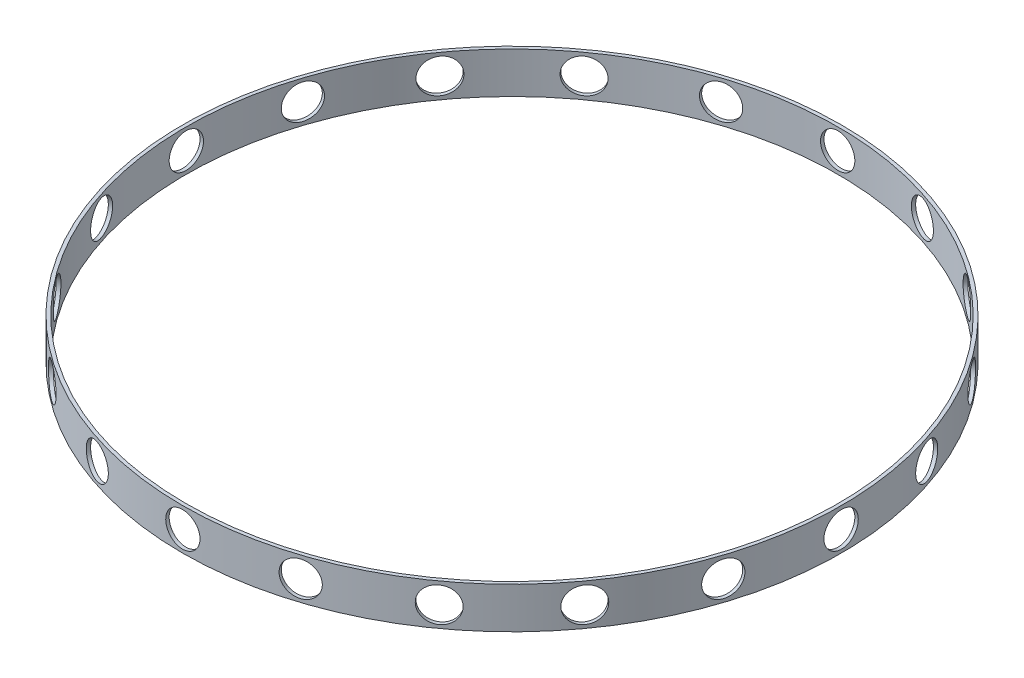
from build123d import *

# Parameters (mm, degrees)
SKETCH1_R           = 48
SKETCH1_R_2         = 47.5
BOSS_EXTRUDE2_DEPTH = 6
SKETCH5_R           = 2.5
CUT_EXTRUDE1_DEPTH  = 49
CIRPATTERN1_COUNT   = 20


with BuildPart() as part:
    # Sketch1 → Boss-Extrude2 (new body)
    with BuildSketch(Plane(origin=(0, 0, 0), x_dir=(1, 0, 0), z_dir=(0, 1, 0))):
        Circle(SKETCH1_R)
        Circle(SKETCH1_R_2, mode=Mode.SUBTRACT)
    extrude(amount=BOSS_EXTRUDE2_DEPTH)

    # Sketch5 → Cut-Extrude1 (cut, symmetric)
    with BuildSketch(Plane.XY):
        with Locations((0, 3)):
            Circle(SKETCH5_R)
    cut_extrude1 = extrude(amount=CUT_EXTRUDE1_DEPTH, both=True, mode=Mode.SUBTRACT)

    # CirPattern1: Cut-Extrude1 ×20 about axis
    cirpattern1_axis = Axis((0, 6, 0), (0, -1, 0))
    for i in range(1, CIRPATTERN1_COUNT):
        add(cut_extrude1.rotate(cirpattern1_axis, i * 360 / CIRPATTERN1_COUNT), mode=Mode.SUBTRACT)


solid = part.part
